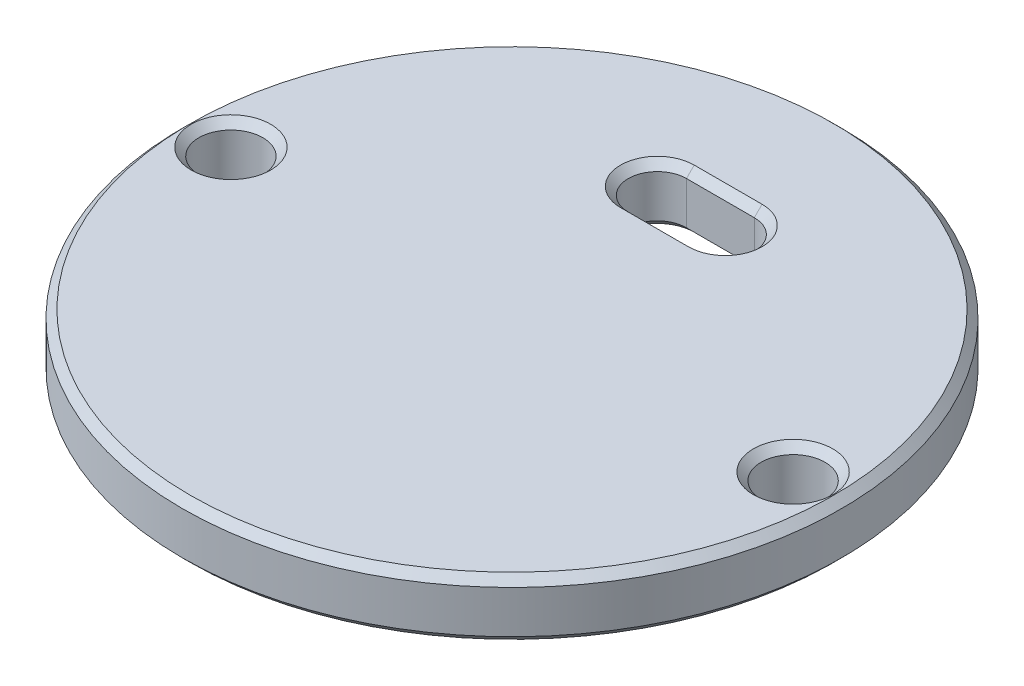
from build123d import *

# Parameters (mm, degrees)
SKETCH1_R           = 17
SKETCH1_R_2         = 1.65
BOSS_EXTRUDE1_DEPTH = 3
CHAMFER1_SIZE       = 0.4


with BuildPart() as part:
    # Sketch1 → Boss-Extrude1 (new body)
    with BuildSketch(Plane(origin=(0, 0, 0), x_dir=(1, 0, 0), z_dir=(0, 1, 0))):
        Circle(SKETCH1_R)
        with Locations((-14.5, 0)):
            Circle(SKETCH1_R_2, mode=Mode.SUBTRACT)
        with Locations((14.5, 0)):
            Circle(SKETCH1_R_2, mode=Mode.SUBTRACT)
        with BuildLine():
            Line((-1.75, 7.75), (1.75, 7.75))
            ThreePointArc((1.75, 7.75), (3.25, 9.25), (1.75, 10.75))
            Line((1.75, 10.75), (-1.75, 10.75))
            ThreePointArc((-1.75, 10.75), (-3.25, 9.25), (-1.75, 7.75))
        make_face(mode=Mode.SUBTRACT)
    extrude(amount=BOSS_EXTRUDE1_DEPTH)

    # Chamfer1
    chamfer1_edges = [part.edges().sort_by_distance(p)[0] for p in [
        (-3.25, 3, -9.25),
        (0, 3, -7.75),
        (-16.15, 0, 0),
        (-16.15, 3, 0),
        (-17, 0, 0),
        (12.85, 0, 0),
        (12.85, 3, 0),
        (-17, 3, 0),
        (3.25, 0, -9.25),
        (0, 0, -10.75),
        (-3.25, 0, -9.25),
        (0, 0, -7.75),
        (3.25, 3, -9.25),
        (0, 3, -10.75),
    ]]
    chamfer(chamfer1_edges, length=CHAMFER1_SIZE)


solid = part.part
